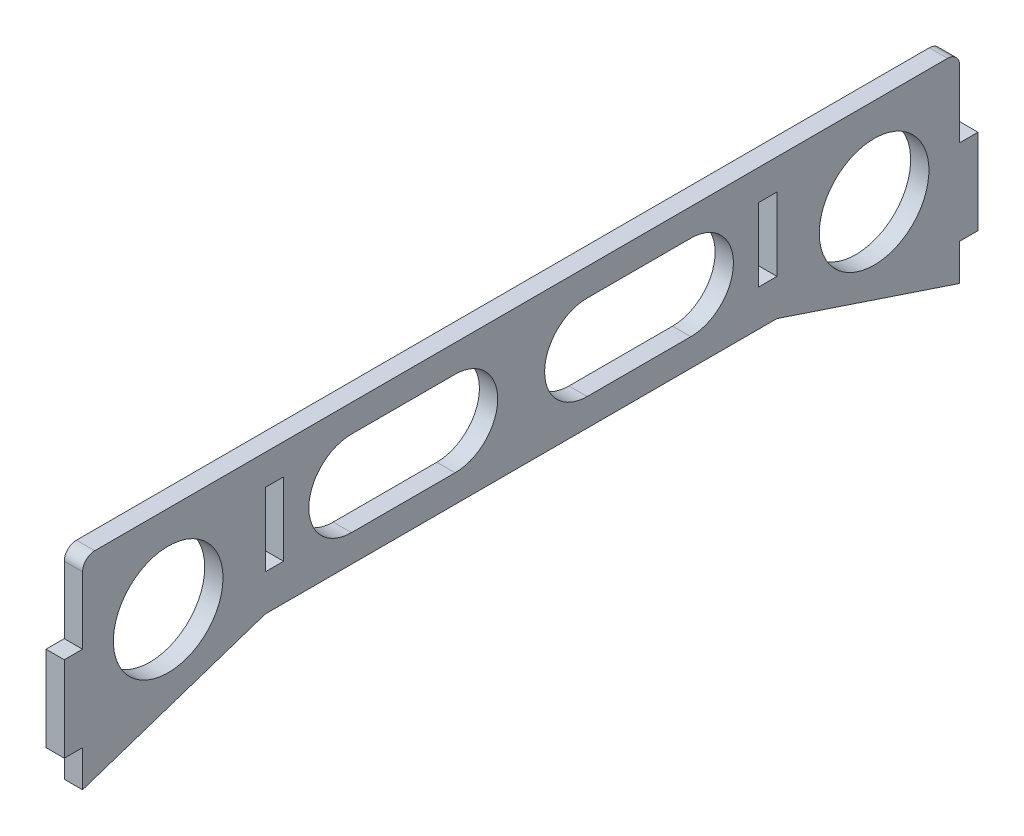
from build123d import *

# Parameters (mm, degrees)
SKETCH1_W           = 144
SKETCH1_H           = 23
BOSS_EXTRUDE1_DEPTH = 3
FILLET1_R           = 2
BOSS_EXTRUDE2_DEPTH = 3
SKETCH3_W           = 3
SKETCH3_H           = 14
BOSS_EXTRUDE3_DEPTH = 3
SKETCH4_R           = 9
SKETCH4_W           = 3
SKETCH4_H           = 12
CUT_EXTRUDE1_DEPTH  = 10


with BuildPart() as part:
    # Sketch1 → Boss-Extrude1 (new body)
    with BuildSketch(Plane(origin=(0, 0, 0), x_dir=(0, 0, -1), z_dir=(1, 0, 0))):
        Rectangle(SKETCH1_W, SKETCH1_H)
    extrude(amount=BOSS_EXTRUDE1_DEPTH)

    # Fillet1
    fillet1_edges = [part.edges().sort_by_distance(p)[0] for p in [
        (1.5, 11.5, 72),
        (1.5, 11.5, -72),
    ]]
    fillet(fillet1_edges, radius=FILLET1_R)

    # Sketch2 → Boss-Extrude2 (add)
    with BuildSketch(Plane(origin=(3, 0, 0), x_dir=(0, 0, -1), z_dir=(1, 0, 0))):
        Polygon((-72, -11.5), (-72, -21.5), (-42, -11.5), align=None)
        Polygon((72, -11.5), (72, -21.5), (42, -11.5), align=None)
    extrude(amount=-BOSS_EXTRUDE2_DEPTH)

    # Sketch3 → Boss-Extrude3 (add)
    with BuildSketch(Plane(origin=(3, 0, 0), x_dir=(0, 0, -1), z_dir=(1, 0, 0))):
        with Locations((-73.5, -8.5)):
            Rectangle(SKETCH3_W, SKETCH3_H)
        with Locations((73.5, -8.5)):
            Rectangle(SKETCH3_W, SKETCH3_H)
    extrude(amount=-BOSS_EXTRUDE3_DEPTH)

    # Sketch4 → Cut-Extrude1 (cut)
    with BuildSketch(Plane(origin=(3, 0, 0), x_dir=(0, 0, -1), z_dir=(1, 0, 0))):
        with Locations((-57.942503038, -2.875250136)):
            Circle(SKETCH4_R)
        with Locations((57.942503038, -2.875250136)):
            Circle(SKETCH4_R)
        with Locations((-40.5, 0.5)):
            Rectangle(SKETCH4_W, SKETCH4_H)
        with Locations((40.5, 0.5)):
            Rectangle(SKETCH4_W, SKETCH4_H)
        with BuildLine():
            Line((-27.851450915, 7), (-10.851450915, 7))
            ThreePointArc((-10.851450915, 7), (-3.851450915, 0), (-10.851450915, -7))
            Line((-10.851450915, -7), (-27.851450915, -7))
            ThreePointArc((-27.851450915, -7), (-34.851450915, 0), (-27.851450915, 7))
        make_face()
        with BuildLine():
            Line((27.851450915, 7), (10.851450915, 7))
            ThreePointArc((10.851450915, 7), (3.851450915, 0), (10.851450915, -7))
            Line((10.851450915, -7), (27.851450915, -7))
            ThreePointArc((27.851450915, -7), (34.851450915, 0), (27.851450915, 7))
        make_face()
    extrude(amount=-CUT_EXTRUDE1_DEPTH, mode=Mode.SUBTRACT)


solid = part.part
